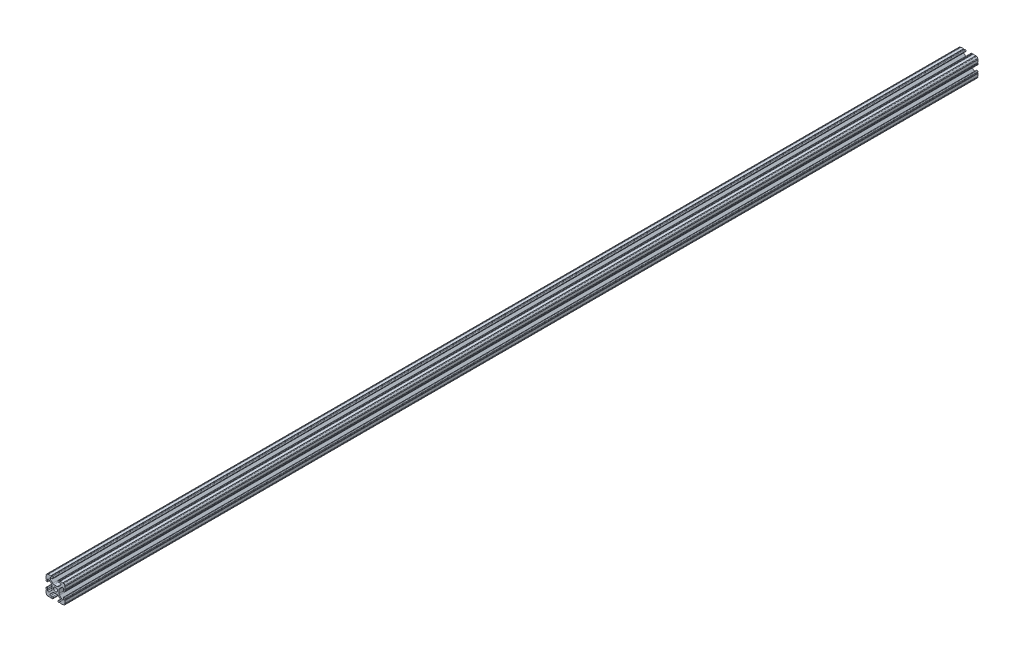
from build123d import *

# Parameters (mm, degrees)
BOSS_EXTRUDE1_DEPTH     = 609.6
SKETCH5_R               = 0.55245
CUT_EXTRUDE1_DEPTH      = 610.6
CUT_EXTRUDE1_DEPTH_BACK = 610.6


with BuildPart() as part:
    # Sketch4 → Boss-Extrude1 (new body, symmetric)
    with BuildSketch(Plane.XY):
        with BuildLine():
            Line((4.190365, -12.7), (10.11729625, -12.7))
            ThreePointArc((10.11729625, -12.7), (11.943543585, -11.943543585), (12.7, -10.11729625))
            Line((12.7, -10.11729625), (12.7, -4.190365))
            ThreePointArc((12.7, -4.190365), (12.42492494, -3.52627506), (11.760835, -3.2512))
            Line((11.760835, -3.2512), (11.429365, -3.2512))
            ThreePointArc((11.429365, -3.2512), (10.76527506, -3.52627506), (10.4902, -4.190365))
            Line((10.4902, -4.190365), (10.4902, -6.348478019))
            ThreePointArc((10.4902, -6.348478019), (9.830707141, -7.335478831), (8.666460301, -7.103895736))
            Line((8.666460301, -7.103895736), (5.299899128, -3.737334563))
            ThreePointArc((5.299899128, -3.737334563), (4.817571085, -3.015479634), (4.6482, -2.16399369))
            Line((4.6482, -2.16399369), (4.6482, 0))
            Line((4.6482, 0), (2.6035, 0))
            ThreePointArc((2.6035, 0), (1.840952505, -1.840952505), (0, -2.6035))
            Line((0, -2.6035), (0, -4.6482))
            Line((0, -4.6482), (2.16399369, -4.6482))
            ThreePointArc((2.16399369, -4.6482), (3.015479634, -4.817571085), (3.737334563, -5.299899128))
            Line((3.737334563, -5.299899128), (7.103895736, -8.666460301))
            ThreePointArc((7.103895736, -8.666460301), (7.335478831, -9.830707141), (6.348478019, -10.4902))
            Line((6.348478019, -10.4902), (4.190365, -10.4902))
            ThreePointArc((4.190365, -10.4902), (3.52627506, -10.76527506), (3.2512, -11.429365))
            Line((3.2512, -11.429365), (3.2512, -11.760835))
            ThreePointArc((3.2512, -11.760835), (3.52627506, -12.42492494), (4.190365, -12.7))
        make_face()
    extrude(amount=BOSS_EXTRUDE1_DEPTH, both=True)

    # Sketch5 → Cut-Extrude1 (cut, two sides)
    with BuildSketch(Plane.XY) as cut_extrude1_sk:
        with Locations((10.356153152, -12.7)):
            Circle(SKETCH5_R)
        with Locations((5.796028019, -12.7)):
            Circle(SKETCH5_R)
        with Locations((12.7, -10.356153152)):
            Circle(SKETCH5_R)
        with Locations((12.7, -5.796028019)):
            Circle(SKETCH5_R)
    extrude(amount=CUT_EXTRUDE1_DEPTH, mode=Mode.SUBTRACT)
    extrude(cut_extrude1_sk.sketch, amount=-CUT_EXTRUDE1_DEPTH_BACK, mode=Mode.SUBTRACT)

    # Mirror1: part across plane


with BuildPart() as part_1:
    add(part.part)
    add(part.part.mirror(Plane(origin=(0, 0, 0), x_dir=(0, 0, 1), z_dir=(1, 0, 0))))

    # Mirror2: part across plane


with BuildPart() as part_2:
    add(part_1.part)
    add(part_1.part.mirror(Plane.ZX))


solid = part_2.part
